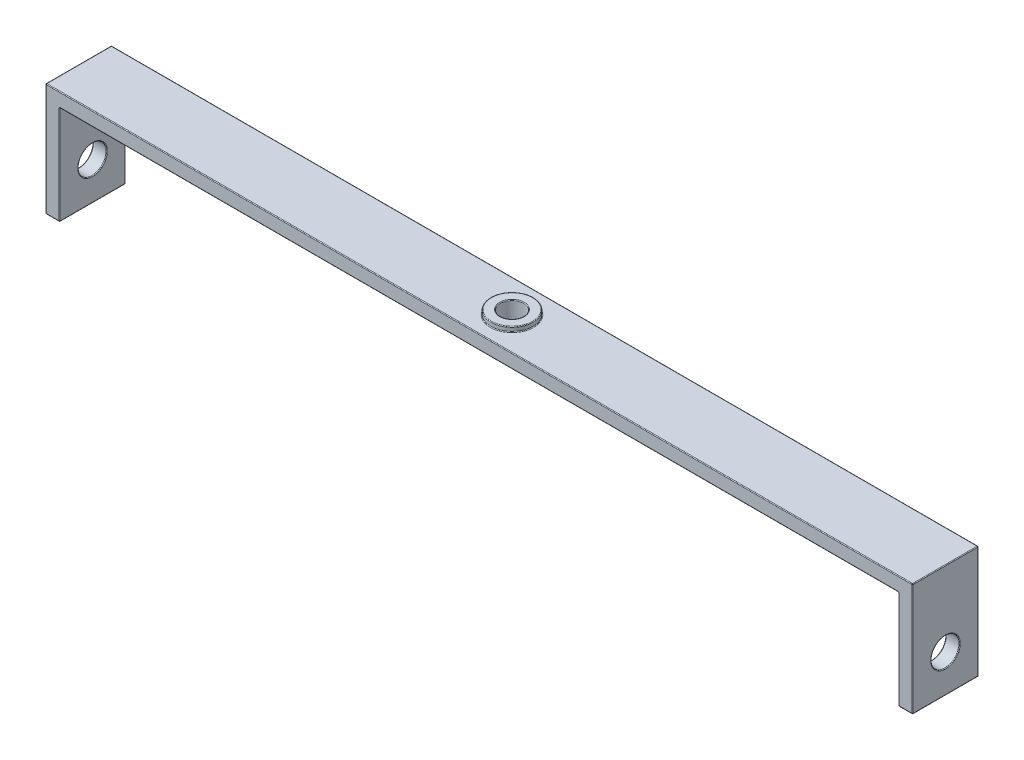
from build123d import *

# Parameters (mm, degrees)
BOSS_EXTRUDE1_DEPTH            = 3.5
BOSS_EXTRUDE1_DEPTH_BACK       = 3.5
SKETCH3_R                      = 1.25
CUT_EXTRUDE1_DEPTH             = 1.5
SKETCH9_R                      = 2.25
SKETCH9_R_2                    = 1.25
BOSS_EXTRUDE5_DEPTH            = 0.5
CUT_EXTRUDE2_REACH             = 48.11
SKETCH11_R                     = 1.5
CUT_EXTRUDE2_DIRECTION_2_REACH = 48.11
FILLET1_R                      = 0.075


with BuildPart() as part:
    # Sketch2 → Boss-Extrude1 (new body, two sides)
    with BuildSketch(Plane.XY) as boss_extrude1_sk:
        Polygon((-46.11, 0), (46.11, 0), (46.11, -12), (44.61, -12), (44.61, -1.5), (-44.61, -1.5), (-44.61, -12), (-46.11, -12), align=None)
    extrude(amount=BOSS_EXTRUDE1_DEPTH)
    extrude(boss_extrude1_sk.sketch, amount=-BOSS_EXTRUDE1_DEPTH_BACK)

    # Sketch3 → Cut-Extrude1 (cut)
    with BuildSketch(Plane(origin=(0, 0, 0), x_dir=(1, 0, 0), z_dir=(0, 1, 0))):
        Circle(SKETCH3_R)
    extrude(amount=-CUT_EXTRUDE1_DEPTH, mode=Mode.SUBTRACT)

    # Sketch9 → Boss-Extrude5 (add)
    with BuildSketch(Plane(origin=(0, 0, 0), x_dir=(1, 0, 0), z_dir=(0, 1, 0))):
        Circle(SKETCH9_R)
        Circle(SKETCH9_R_2, mode=Mode.SUBTRACT)
    extrude(amount=BOSS_EXTRUDE5_DEPTH)

    # Cut-Extrude2: up to this face of the body (flat: up to its plane)
    cut_extrude2_end = Plane(part.part.faces().sort_by_distance((46.11, -6, 0))[0])
    # Sketch11 → Cut-Extrude2 (cut, up to the picked face)
    with BuildSketch(Plane(origin=(0, 0, 0), x_dir=(0, 0, -1), z_dir=(1, 0, 0)), mode=Mode.PRIVATE) as cut_extrude2_sk1:
        with Locations((0, -8)):
            Circle(SKETCH11_R)
    cut_extrude2_tool1 = split(extrude(cut_extrude2_sk1.sketch, amount=CUT_EXTRUDE2_REACH, mode=Mode.PRIVATE), bisect_by=cut_extrude2_end, keep=Keep.BOTH, mode=Mode.PRIVATE)
    add(cut_extrude2_tool1.solids().sort_by_distance((0, -8, 0))[0], mode=Mode.SUBTRACT)

    # Cut-Extrude2 direction 2: up to this face of the body (flat: up to its plane)
    cut_extrude2_direction_2_end = Plane(part.part.faces().sort_by_distance((-46.11, -6, 0))[0])
    # Sketch11 → Cut-Extrude2 direction 2 (cut, up to the picked face)
    with BuildSketch(Plane(origin=(0, 0, 0), x_dir=(0, 0, -1), z_dir=(1, 0, 0)), mode=Mode.PRIVATE) as cut_extrude2_direction_2_sk1:
        with Locations((0, -8)):
            Circle(SKETCH11_R)
    cut_extrude2_direction_2_tool1 = split(extrude(cut_extrude2_direction_2_sk1.sketch, amount=-CUT_EXTRUDE2_DIRECTION_2_REACH, mode=Mode.PRIVATE), bisect_by=cut_extrude2_direction_2_end, keep=Keep.BOTH, mode=Mode.PRIVATE)
    add(cut_extrude2_direction_2_tool1.solids().sort_by_distance((0, -8, 0))[0], mode=Mode.SUBTRACT)

    # Fillet1
    fillet1_edges = [part.edges().sort_by_distance(p)[0] for p in [
        (-44.61, -6.75, -3.5),
        (-46.11, 0, 0),
        (46.11, 0, 0),
        (46.11, -12, 0),
        (44.61, -12, 0),
        (44.61, -1.5, 0),
        (-44.61, -1.5, 0),
        (-44.61, -12, 0),
        (-46.11, -12, 0),
        (0, -1.5, -3.5),
        (44.61, -6.75, -3.5),
        (-46.11, -6, 3.5),
        (-45.36, -12, 3.5),
        (-44.61, -6.75, 3.5),
        (0, -1.5, 3.5),
        (44.61, -6.75, 3.5),
        (45.36, -12, -3.5),
        (45.36, -12, 3.5),
        (46.11, -6, 3.5),
        (0, 0, 3.5),
        (46.11, -6, -3.5),
        (0, 0, -3.5),
        (-1.25, -1.5, 0),
        (-2.25, 0.5, 0),
        (-2.25, 0, 0),
        (-1.25, 0.5, 0),
        (-46.11, -6, -3.5),
        (44.61, -8, 1.5),
        (-44.61, -8, 1.5),
        (-46.11, -8, 1.5),
        (46.11, -8, 1.5),
        (-45.36, -12, -3.5),
    ]]
    fillet(fillet1_edges, radius=FILLET1_R)


solid = part.part
